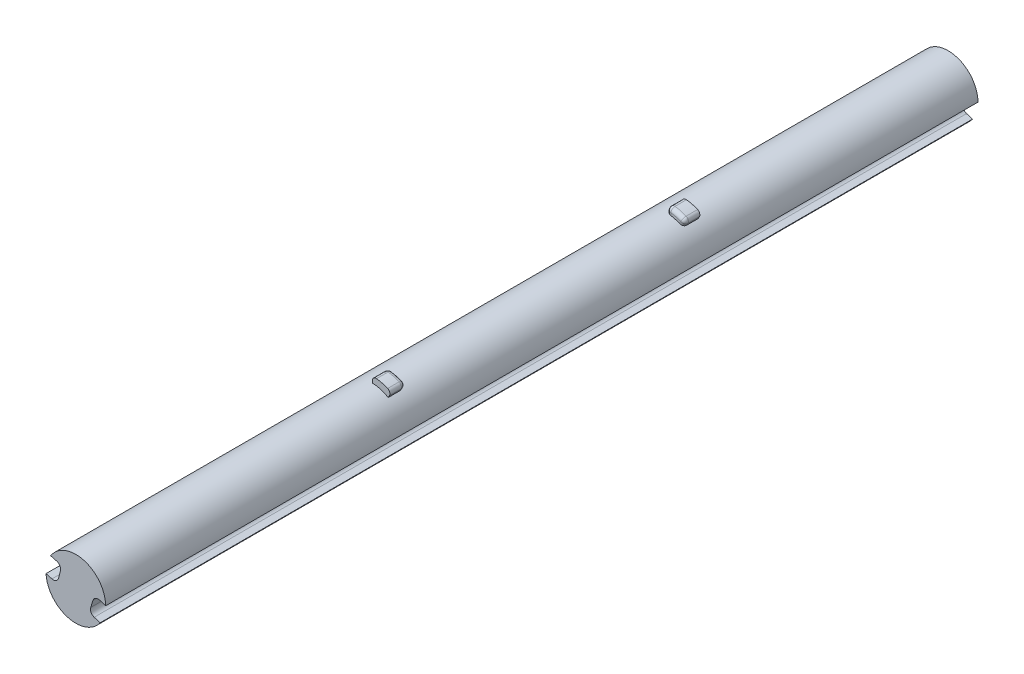
from build123d import *

# Parameters (mm, degrees)
SZKIC1_R                    = 3.9
DODANIE_WYCI_GNI_CIE1_DEPTH = 114
SZKIC4_W                    = 2
SZKIC4_H                    = 5
OBR_T1_ANGLE                = 30
ZAOKR_GLENIE5_R             = 0.5
WYTNIJ_WYCI_GNI_CIE1_DEPTH  = 114
WYTNIJ_WYCI_GNI_CIE2_DEPTH  = 11.5


with BuildPart() as part:
    # Szkic1 → Dodanie-wyci_gni_cie1 (new body)
    with BuildSketch(Plane.XY):
        Circle(SZKIC1_R)
    extrude(amount=DODANIE_WYCI_GNI_CIE1_DEPTH)

    # Szkic4 → Obr_t1 (revolve)
    with BuildSketch(Plane(origin=(0, 0, 0), x_dir=(0, 0, -1), z_dir=(1, 0, 0))):
        with Locations((-74.25, 2.217381868)):
            Rectangle(SZKIC4_W, SZKIC4_H)
        with Locations((-35.75, 2.217381868)):
            Rectangle(SZKIC4_W, SZKIC4_H)
    revolve(axis=Axis((0, -0.282618132, 75.25), (0, 0, -1)), revolution_arc=OBR_T1_ANGLE)

    # Zaokr_glenie5
    zaokr_glenie5_edges = [part.edges().sort_by_distance(p)[0] for p in [
        (0, 4.717381868, 74.25),
        (2.5, 4.047508887, 74.25),
        (0, 4.308690934, 73.25),
        (2.285548402, 3.676067824, 73.25),
        (1.294095226, 4.547010999, 73.25),
        (0, 4.308690934, 36.75),
        (2.285548402, 3.676067824, 36.75),
        (1.294095226, 4.547010999, 36.75),
        (2.5, 4.047508887, 35.75),
        (0, 4.717381868, 35.75),
    ]]
    fillet(zaokr_glenie5_edges, radius=ZAOKR_GLENIE5_R)

    # Szkic5 → Wytnij-wyci_gni_cie1 (cut)
    with BuildSketch(Plane.XY.offset(114)):
        with BuildLine():
            Line((2.24849307, -0.185145655), (1.947595825, -1.138802222))
            ThreePointArc((1.947595825, -1.138802222), (1.994182967, -1.672529674), (2.404527351, -2.016989891))
            Line((2.404527351, -2.016989891), (3.548915231, -2.378066585))
            Line((3.548915231, -2.378066585), (3.909991925, -1.233678704))
            Line((3.909991925, -1.233678704), (4.271068619, -0.089290824))
            Line((4.271068619, -0.089290824), (3.126680739, 0.27178587))
            ThreePointArc((3.126680739, 0.27178587), (2.592953287, 0.225198729), (2.24849307, -0.185145655))
        make_face()
    extrude(amount=-WYTNIJ_WYCI_GNI_CIE1_DEPTH, mode=Mode.SUBTRACT)

    # Szkic5_3 → Wytnij-wyci_gni_cie2 (cut)
    with BuildSketch(Plane.XY.offset(114)):
        with BuildLine():
            Line((-3.66646605, 2.192493262), (-2.505030255, 1.890720345))
            ThreePointArc((-2.505030255, 1.890720345), (-2.077521655, 1.567808977), (-2.003560242, 1.03718193))
            Line((-2.003560242, 1.03718193), (-2.255037673, 0.069318767))
            ThreePointArc((-2.255037673, 0.069318767), (-2.577949041, -0.358189833), (-3.108576089, -0.432151245))
            Line((-3.108576089, -0.432151245), (-4.270011884, -0.130378328))
            Line((-4.270011884, -0.130378328), (-3.968238967, 1.031057467))
            Line((-3.968238967, 1.031057467), (-3.66646605, 2.192493262))
        make_face()
    extrude(amount=-WYTNIJ_WYCI_GNI_CIE2_DEPTH, mode=Mode.SUBTRACT)


solid = part.part
